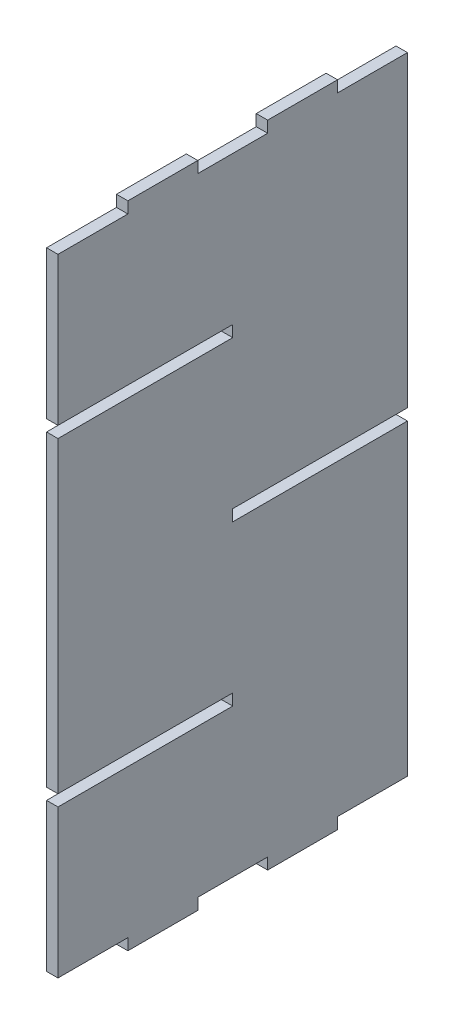
from build123d import *

# Parameters (mm, degrees)
ESTRUSIONE_ESTRUSIONE1_DEPTH = 1.5


with BuildPart() as part:
    # Schizzo1 → Estrusione-Estrusione1 (new body, symmetric)
    with BuildSketch(Plane(origin=(0, 0, 0), x_dir=(0, 0, -1), z_dir=(1, 0, 0))):
        Polygon((-46, -82.5), (-46, -43.5), (0, -43.5), (0, -40.5), (-46, -40.5), (-46, 40.5), (0, 40.5), (0, 43.5), (-46, 43.5), (-46, 82.5), (-27.6, 82.5), (-27.6, 85.5), (-9.2, 85.5), (-9.2, 82.5), (9.2, 82.5), (9.2, 85.5), (27.6, 85.5), (27.6, 82.5), (46, 82.5), (46, 1.5), (0, 1.5), (0, -1.5), (46, -1.5), (46, -82.5), (27.6, -82.5), (27.6, -85.5), (9.2, -85.5), (9.2, -82.5), (-9.2, -82.5), (-9.2, -85.5), (-27.6, -85.5), (-27.6, -82.5), align=None)
    extrude(amount=ESTRUSIONE_ESTRUSIONE1_DEPTH, both=True)


solid = part.part
